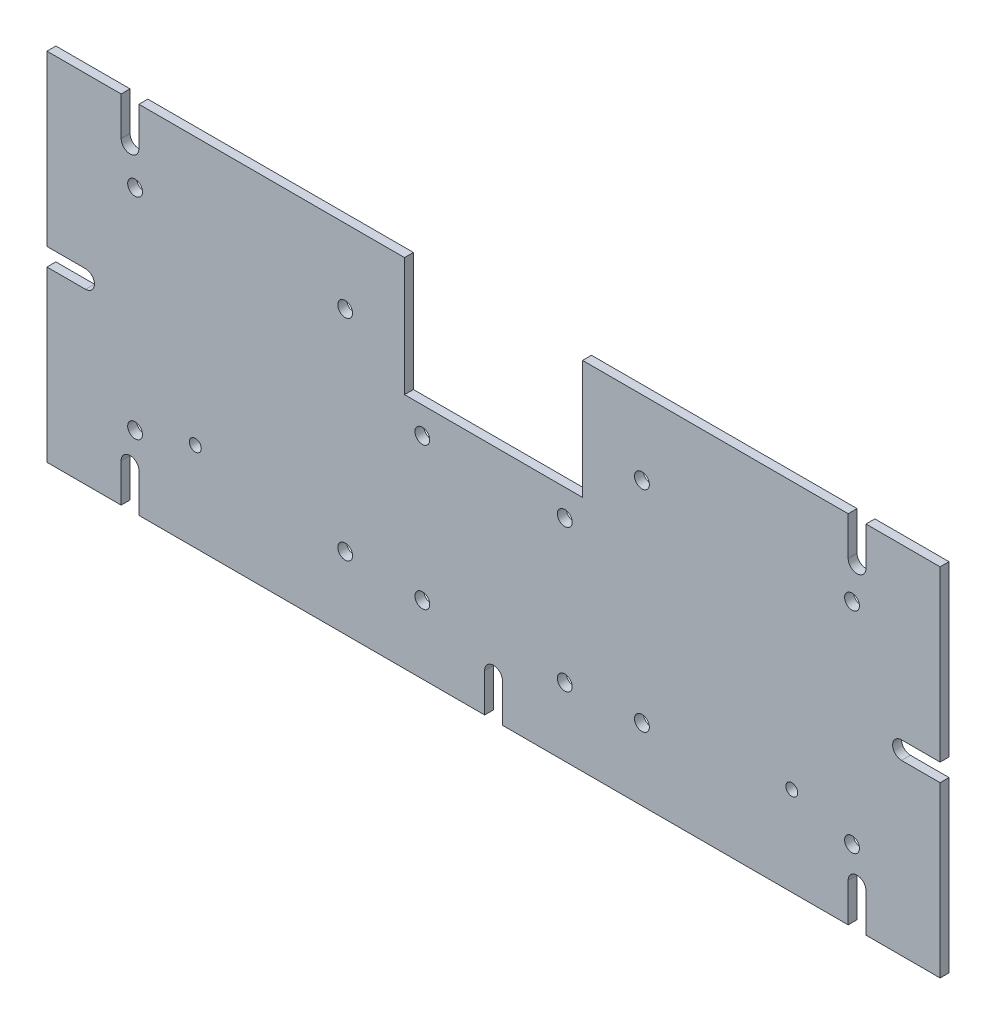
from build123d import *

# Parameters (mm, degrees)
SKETCH1_W           = 301
SKETCH1_H           = 120
BOSS_EXTRUDE1_DEPTH = 3
SKETCH2_W           = 60
SKETCH2_H           = 40
CUT_EXTRUDE1_DEPTH  = 3
CUT_EXTRUDE2_DEPTH  = 10
SKETCH5_R           = 2.5
CUT_EXTRUDE3_DEPTH  = 10
SKETCH6_R           = 2.5
CUT_EXTRUDE4_DEPTH  = 10
SKETCH7_R           = 2
CUT_EXTRUDE5_DEPTH  = 10


with BuildPart() as part:
    # Sketch1 → Boss-Extrude1 (new body)
    with BuildSketch(Plane.XY):
        Rectangle(SKETCH1_W, SKETCH1_H)
    extrude(amount=BOSS_EXTRUDE1_DEPTH)

    # Sketch2 → Cut-Extrude1 (cut)
    with BuildSketch(Plane.XY.offset(3)):
        with Locations((0, 40)):
            Rectangle(SKETCH2_W, SKETCH2_H)
    extrude(amount=-CUT_EXTRUDE1_DEPTH, mode=Mode.SUBTRACT)

    # Sketch4 → Cut-Extrude2 (cut)
    with BuildSketch(Plane.XY.offset(3)):
        with BuildLine():
            Line((-125.5, -47), (-125.5, -60))
            Line((-125.5, -60), (-119.5, -60))
            Line((-119.5, -60), (-119.5, -47))
            ThreePointArc((-119.5, -47), (-122.5, -44), (-125.5, -47))
        make_face()
        with BuildLine():
            Line((-150.5, 3), (-150.5, -3))
            Line((-150.5, -3), (-137.5, -3))
            ThreePointArc((-137.5, -3), (-134.5, 0), (-137.5, 3))
            Line((-137.5, 3), (-150.5, 3))
        make_face()
        with BuildLine():
            Line((119.5, -47), (119.5, -60))
            Line((119.5, -60), (125.5, -60))
            Line((125.5, -60), (125.5, -47))
            ThreePointArc((125.5, -47), (122.5, -44), (119.5, -47))
        make_face()
        with BuildLine():
            Line((137.5, -3), (150.5, -3))
            Line((150.5, -3), (150.5, 3))
            Line((150.5, 3), (137.5, 3))
            ThreePointArc((137.5, 3), (134.5, 0), (137.5, -3))
        make_face()
        with BuildLine():
            Line((125.5, 47), (125.5, 60))
            Line((125.5, 60), (119.5, 60))
            Line((119.5, 60), (119.5, 47))
            ThreePointArc((119.5, 47), (122.5, 44), (125.5, 47))
        make_face()
        with BuildLine():
            Line((-119.5, 47), (-119.5, 60))
            Line((-119.5, 60), (-125.5, 60))
            Line((-125.5, 60), (-125.5, 47))
            ThreePointArc((-125.5, 47), (-122.5, 44), (-119.5, 47))
        make_face()
        with BuildLine():
            Line((3, -47), (3, -60))
            Line((3, -60), (-3, -60))
            Line((-3, -60), (-3, -47))
            ThreePointArc((-3, -47), (0, -44), (3, -47))
        make_face()
    extrude(amount=-CUT_EXTRUDE2_DEPTH, mode=Mode.SUBTRACT)

    # Sketch5 → Cut-Extrude3 (cut)
    with BuildSketch(Plane.XY.offset(3)):
        with Locations((120.8, 35)):
            Circle(SKETCH5_R)
        with Locations((120.8, -35.8)):
            Circle(SKETCH5_R)
        with Locations((50, -35.8)):
            Circle(SKETCH5_R)
        with Locations((50, 35)):
            Circle(SKETCH5_R)
    cut_extrude3 = extrude(amount=-CUT_EXTRUDE3_DEPTH, mode=Mode.SUBTRACT)

    # Mirror1: Cut-Extrude3 across plane
    add(cut_extrude3.mirror(Plane.ZY), mode=Mode.SUBTRACT)

    # Sketch6 → Cut-Extrude4 (cut)
    with BuildSketch(Plane.XY.offset(3)):
        with Locations((24, 11)):
            Circle(SKETCH6_R)
        with Locations((-24, 11)):
            Circle(SKETCH6_R)
        with Locations((-24, -37)):
            Circle(SKETCH6_R)
        with Locations((24, -37)):
            Circle(SKETCH6_R)
    extrude(amount=-CUT_EXTRUDE4_DEPTH, mode=Mode.SUBTRACT)

    # Sketch7 → Cut-Extrude5 (cut)
    with BuildSketch(Plane.XY.offset(3)):
        with Locations((-100.5, -30)):
            Circle(SKETCH7_R)
        with Locations((100.5, -30)):
            Circle(SKETCH7_R)
    extrude(amount=-CUT_EXTRUDE5_DEPTH, mode=Mode.SUBTRACT)


solid = part.part
